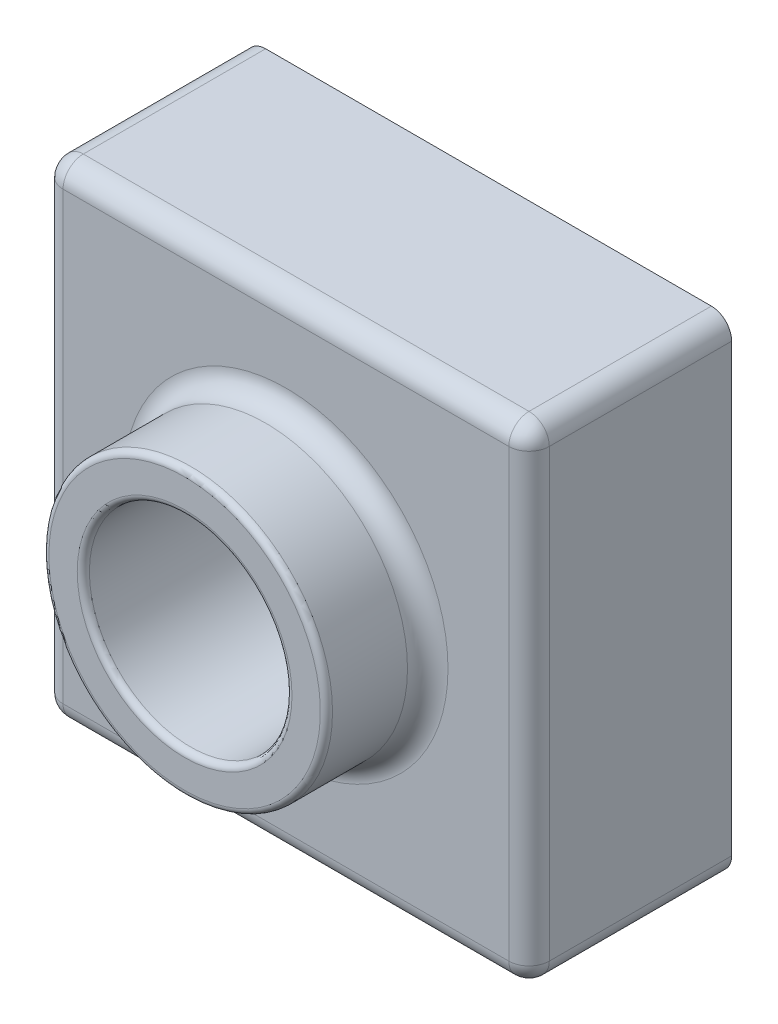
from build123d import *

# Parameters (mm, degrees)
SKETCH1_W             = 120
SKETCH1_H             = 120
BOSS_EXTRUDE1_DEPTH   = 50
SKETCH2_R             = 35
BOSS_EXTRUDE2_DEPTH   = 25
SKETCH3_R             = 25
CUT_EXTRUDE1_DEPTH    = 186.539753153
FILLET2_R             = 5
FILLET3_R             = 1.5
SHELL1_T              = -2
BODY_MOVE_COPY1_ANGLE = 90
BODY_MOVE_COPY2_ANGLE = 90


with BuildPart() as part:
    # Sketch1 → Boss-Extrude1 (new body)
    with BuildSketch(Plane(origin=(0, 0, 0), x_dir=(1, 0, 0), z_dir=(0, 1, 0))):
        with Locations((60, 60)):
            Rectangle(SKETCH1_W, SKETCH1_H)
    extrude(amount=BOSS_EXTRUDE1_DEPTH)

    # Sketch2 → Boss-Extrude2 (add)
    with BuildSketch(Plane(origin=(0, 50, 0), x_dir=(1, 0, 0), z_dir=(0, 1, 0))):
        with Locations(Location((60, 60, 0), (0, 0, 270))):
            Circle(SKETCH2_R)
    extrude(amount=BOSS_EXTRUDE2_DEPTH)

    # Sketch3 → Cut-Extrude1 (cut, through all)
    with BuildSketch(Plane(origin=(0, 75, 0), x_dir=(1, 0, 0), z_dir=(0, 1, 0))):
        with Locations(Location((60, 60, 0), (0, 0, 270))):
            Circle(SKETCH3_R)
    extrude(amount=-CUT_EXTRUDE1_DEPTH, mode=Mode.SUBTRACT)

    # Fillet2
    fillet2_edges = [part.edges().sort_by_distance(p)[0] for p in [
        (120, 50, -60),
        (60, 50, -120),
        (60, 50, -95),
        (0, 50, -60),
        (60, 50, 0),
        (0, 25, -120),
        (120, 25, -120),
        (120, 25, 0),
        (0, 25, 0),
    ]]
    fillet(fillet2_edges, radius=FILLET2_R)

    # Fillet3
    fillet3_edges = [part.edges().sort_by_distance(p)[0] for p in [
        (60, 75, -95),
        (60, 75, -85),
    ]]
    fillet(fillet3_edges, radius=FILLET3_R)

    # Shell1
    shell1_openings = [part.faces().sort_by_distance(p)[0] for p in [
        (60, 0, -1.697056275),
    ]]
    offset(amount=SHELL1_T, openings=shell1_openings, kind=Kind.INTERSECTION)


with BuildPart() as part_1:
    # Body-Move/Copy1: moved
    add(part.part.rotate(Axis((60, 37.5, 0), (0, 0, -1)), BODY_MOVE_COPY1_ANGLE))


with BuildPart() as part_2:
    # Body-Move/Copy2: moved
    add(part_1.part.rotate(Axis((60, 0, -60), (0, -1, 0)), BODY_MOVE_COPY2_ANGLE))


solid = part_2.part
